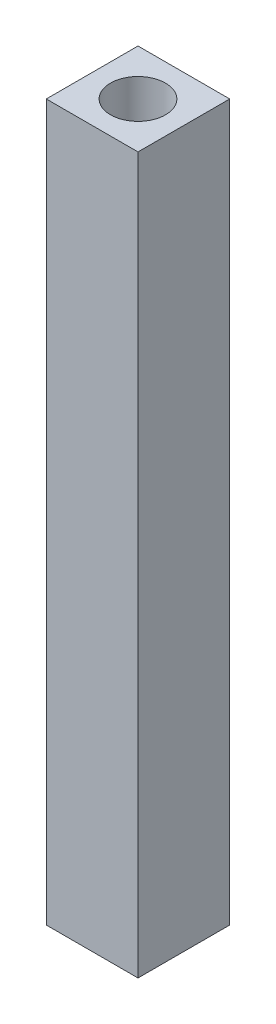
from build123d import *

# Parameters (mm, degrees)
SKETCH1_W           = 5
SKETCH1_H           = 5
SKETCH1_R           = 1.5
BOSS_EXTRUDE1_DEPTH = 39


with BuildPart() as part:
    # Sketch1 → Boss-Extrude1 (new body)
    with BuildSketch(Plane(origin=(0, 0, 0), x_dir=(1, 0, 0), z_dir=(0, 1, 0))):
        Rectangle(SKETCH1_W, SKETCH1_H)
        Circle(SKETCH1_R, mode=Mode.SUBTRACT)
    extrude(amount=BOSS_EXTRUDE1_DEPTH)


solid = part.part
